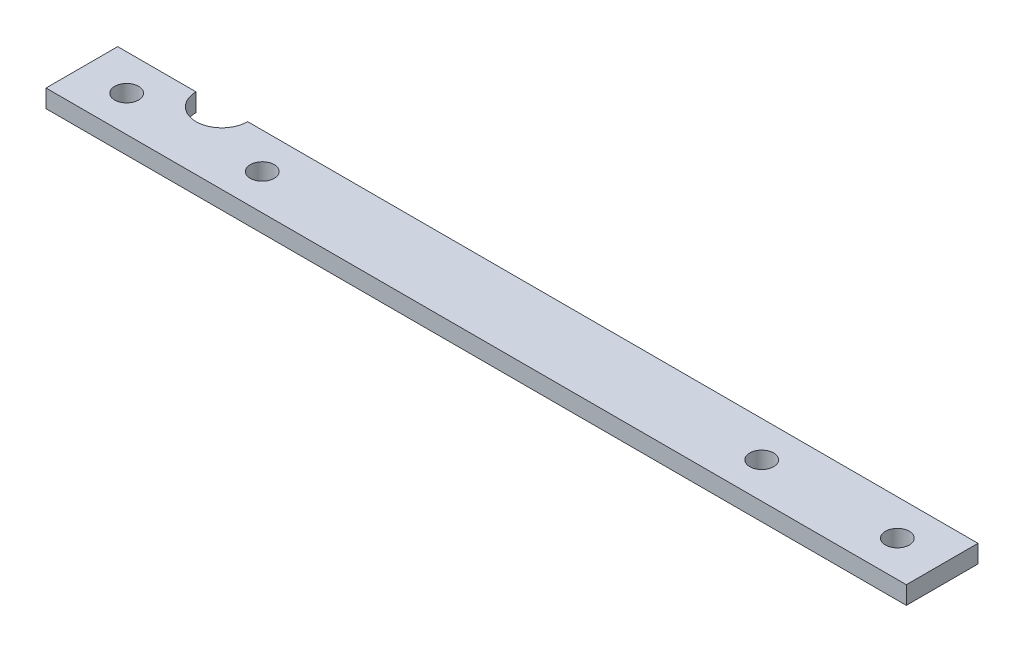
from build123d import *

# Parameters (mm, degrees)
SKETCH1_W           = 228.6
SKETCH1_H           = 19.05
BOSS_EXTRUDE1_DEPTH = 4.7625
SKETCH2_R           = 3.175
CUT_EXTRUDE1_DEPTH  = 5.7625
SKETCH3_R           = 6.858
CUT_EXTRUDE2_DEPTH  = 5.7625
SKETCH4_R           = 3.175
CUT_EXTRUDE3_DEPTH  = 5.7625


with BuildPart() as part:
    # Sketch1 → Boss-Extrude1 (new body)
    with BuildSketch(Plane(origin=(0, 0, 0), x_dir=(1, 0, 0), z_dir=(0, 1, 0))):
        Rectangle(SKETCH1_W, SKETCH1_H)
    extrude(amount=BOSS_EXTRUDE1_DEPTH)

    # Sketch2 → Cut-Extrude1 (cut, through all)
    with BuildSketch(Plane(origin=(0, 4.7625, 0), x_dir=(1, 0, 0), z_dir=(0, 1, 0))):
        with Locations(Location((102.39375, 0, 0), (0, 0, 270))):  # turned: the seam where the file's is
            Circle(SKETCH2_R)
        with Locations(Location((-102.39375, 0, 0), (0, 0, 90))):  # turned: the seam where the file's is
            Circle(SKETCH2_R)
    extrude(amount=-CUT_EXTRUDE1_DEPTH, mode=Mode.SUBTRACT)

    # Sketch3 → Cut-Extrude2 (cut, through all)
    with BuildSketch(Plane(origin=(0, 4.7625, 0), x_dir=(1, 0, 0), z_dir=(0, 1, 0))):
        with Locations((-86.614, 9.525)):
            Circle(SKETCH3_R)
    extrude(amount=-CUT_EXTRUDE2_DEPTH, mode=Mode.SUBTRACT)

    # Sketch4 → Cut-Extrude3 (cut, through all)
    with BuildSketch(Plane(origin=(0, 4.7625, 0), x_dir=(1, 0, 0), z_dir=(0, 1, 0))):
        with Locations(Location((-66.3575, 0, 0), (0, 0, 270))):  # turned: the seam where the file's is
            Circle(SKETCH4_R)
        with Locations(Location((66.3575, 0, 0), (0, 0, 270))):  # turned: the seam where the file's is
            Circle(SKETCH4_R)
    extrude(amount=-CUT_EXTRUDE3_DEPTH, mode=Mode.SUBTRACT)


solid = part.part
